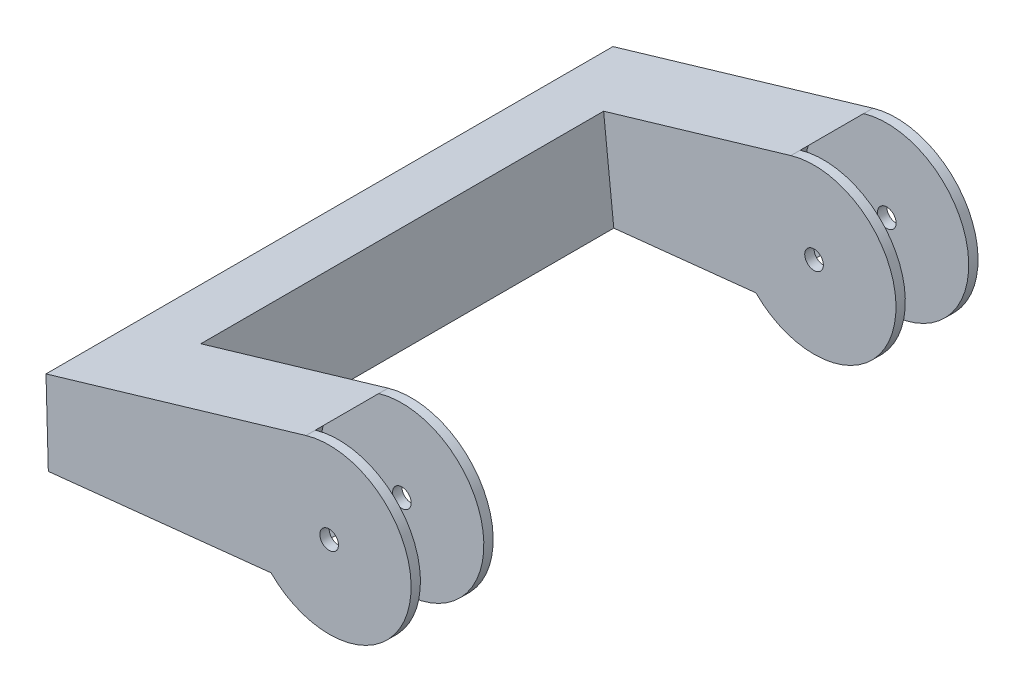
from build123d import *

# Parameters (mm, degrees)
SKETCH1_R           = 2.5
BOSS_EXTRUDE1_DEPTH = 11
SKETCH2_R           = 21.969303103
CUT_EXTRUDE1_DEPTH  = 8.5
BOSS_EXTRUDE2_DEPTH = 54


with BuildPart() as part:
    # Sketch1 → Boss-Extrude1 (new body, symmetric)
    with BuildSketch(Plane.XY):
        with BuildLine():
            Line((-75.294135102, -21.801947472), (-75.916524457, 0.530755))
            Line((-75.916524457, 0.530755), (-6.210315137, 21.073259471))
            ThreePointArc((-6.210315137, 21.073259471), (21.281751318, -5.453195364), (-15.579203419, -15.489954799))
            Line((-15.579203419, -15.489954799), (-75.294135102, -21.801947472))
        make_face()
        Circle(SKETCH1_R, mode=Mode.SUBTRACT)
    boss_extrude1 = extrude(amount=BOSS_EXTRUDE1_DEPTH, both=True)

    # Sketch2 → Cut-Extrude1 (cut, symmetric)
    with BuildSketch(Plane.XY):
        Circle(SKETCH2_R)
    cut_extrude1 = extrude(amount=CUT_EXTRUDE1_DEPTH, both=True, mode=Mode.SUBTRACT)

    # Sketch3 → Boss-Extrude2 (add)
    with BuildSketch(Plane(origin=(0, 0, -11), x_dir=(-1, 0, 0), z_dir=(0, 0, -1))):
        Polygon((75.294135102, -21.801947472), (75.916524457, 0.530755), (75.60532978, 0.622464449), (56.412661227, 6.278567161), (53.685919424, -19.517914062), align=None)
    boss_extrude2 = extrude(amount=BOSS_EXTRUDE2_DEPTH)

    # Mirror3: Boss-Extrude1, Cut-Extrude1, Boss-Extrude2 across plane
    add(boss_extrude1.mirror(Plane(origin=(-98.145469491, -3.551481911, -65), x_dir=(1, 0, 0), z_dir=(0, 0, 1))))
    add(cut_extrude1.mirror(Plane(origin=(-98.145469491, -3.551481911, -65), x_dir=(1, 0, 0), z_dir=(0, 0, 1))), mode=Mode.SUBTRACT)
    add(boss_extrude2.mirror(Plane(origin=(-98.145469491, -3.551481911, -65), x_dir=(1, 0, 0), z_dir=(0, 0, 1))))


solid = part.part
